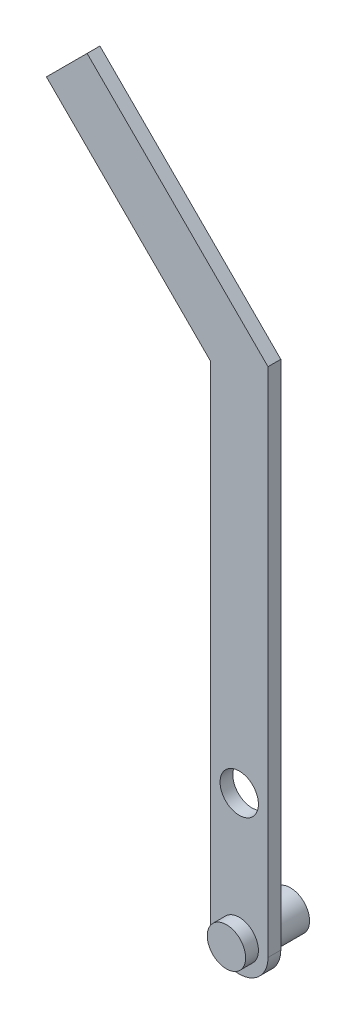
from build123d import *

# Parameters (mm, degrees)
SKETCH_1_R           = 3
EXTRUDE_1_DEPTH      = 2
SKETCH_2_R           = 3
EXTRUDE_2_DEPTH      = 2
EXTRUDE_2_DEPTH_BACK = 8
EXTRUDE_4_DEPTH      = 2
SCALE_1_SCALE        = 3.5


with BuildPart() as part:
    # 草图1 → 凸台-拉伸1 (new body)
    with BuildSketch(Plane.XY):
        with BuildLine():
            Line((-4.5, -20), (-4.5, 20))
            ThreePointArc((-4.5, 20), (0, 24.5), (4.5, 20))
            Line((4.5, 20), (4.5, -20))
            ThreePointArc((4.5, -20), (0, -24.5), (-4.5, -20))
        make_face()
        Circle(SKETCH_1_R, mode=Mode.SUBTRACT)
    extrude(amount=EXTRUDE_1_DEPTH)

    # 草图2 → 凸台-拉伸2 (add, two sides)
    with BuildSketch(Plane.XY.offset(2)) as extrude_2_sk:
        with Locations((0, -19.804668681)):
            Circle(SKETCH_2_R)
    extrude(amount=EXTRUDE_2_DEPTH)
    extrude(extrude_2_sk.sketch, amount=-EXTRUDE_2_DEPTH_BACK)

    # 草图3 → 凸台-拉伸4 (add)
    with BuildSketch(Plane.XY.offset(2)):
        Polygon((-4.5, 20), (-4.5, 56.272077939), (-30.148232278, 81.920310217), (-23.784271247, 88.284271247), (4.5, 60), (4.5, 20), align=None)
    extrude(amount=-EXTRUDE_4_DEPTH)


with BuildPart() as part_1:
    # 缩放比例1: scaled about (-3.938760867, 30.155336672, 0.75690128)
    add(part.part.scale(SCALE_1_SCALE).moved(Location((9.846902167, -75.38834168, -1.8922532))))


solid = part_1.part
